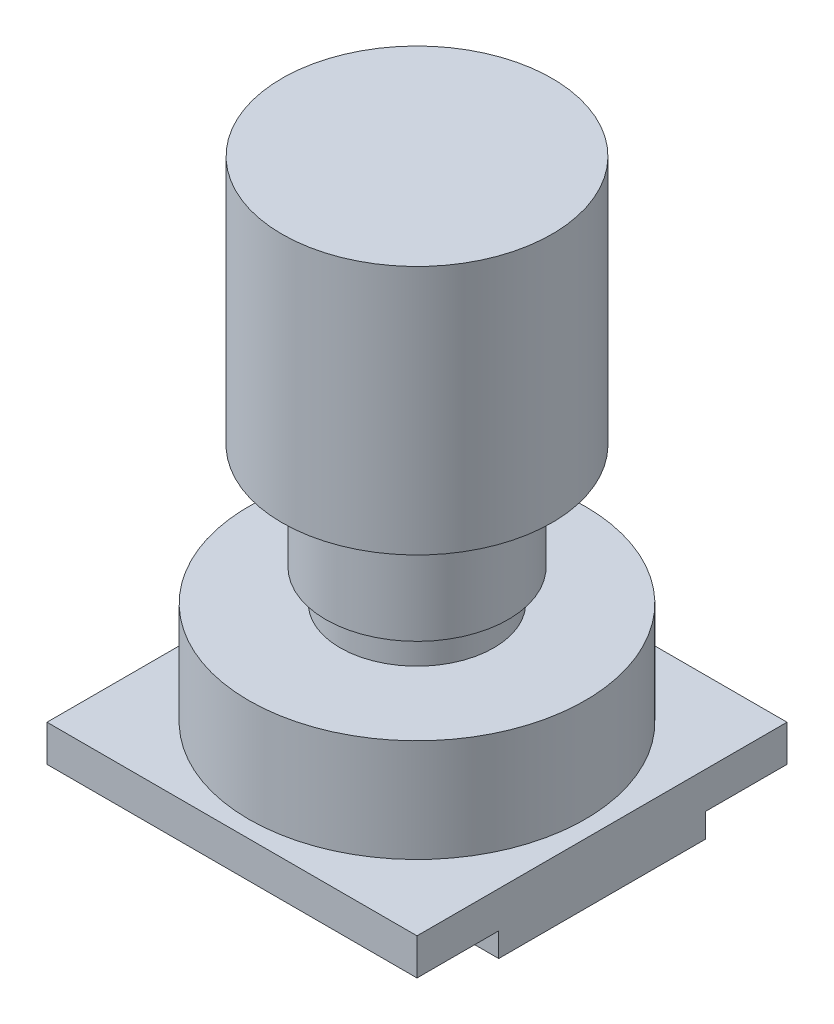
from build123d import *

# Parameters (mm, degrees)
SKETCH1_W           = 38.5
SKETCH1_H           = 38.5
BOSS_EXTRUDE1_DEPTH = 3.8
SKETCH2_R           = 17.5
BOSS_EXTRUDE2_DEPTH = 10.7
SKETCH3_R           = 8
BOSS_EXTRUDE3_DEPTH = 3.3
SKETCH4_R           = 9.5
BOSS_EXTRUDE4_DEPTH = 11
SKETCH5_R           = 14.05
BOSS_EXTRUDE5_DEPTH = 26
SKETCH7_W           = 6
SKETCH7_H           = 21.5
BOSS_EXTRUDE6_DEPTH = 2.5


with BuildPart() as part:
    # Sketch1 → Boss-Extrude1 (new body)
    with BuildSketch(Plane(origin=(0, 0, 0), x_dir=(1, 0, 0), z_dir=(0, 1, 0))):
        Rectangle(SKETCH1_W, SKETCH1_H)
    extrude(amount=BOSS_EXTRUDE1_DEPTH)

    # Sketch2 → Boss-Extrude2 (add)
    with BuildSketch(Plane(origin=(0, 3.8, 0), x_dir=(1, 0, 0), z_dir=(0, 1, 0))):
        Circle(SKETCH2_R)
    extrude(amount=BOSS_EXTRUDE2_DEPTH)

    # Sketch3 → Boss-Extrude3 (add)
    with BuildSketch(Plane(origin=(0, 14.5, 0), x_dir=(1, 0, 0), z_dir=(0, 1, 0))):
        Circle(SKETCH3_R)
    extrude(amount=BOSS_EXTRUDE3_DEPTH)

    # Sketch4 → Boss-Extrude4 (add)
    with BuildSketch(Plane(origin=(0, 17.8, 0), x_dir=(1, 0, 0), z_dir=(0, 1, 0))):
        Circle(SKETCH4_R)
    extrude(amount=BOSS_EXTRUDE4_DEPTH)

    # Sketch5 → Boss-Extrude5 (add)
    with BuildSketch(Plane(origin=(0, 28.8, 0), x_dir=(1, 0, 0), z_dir=(0, 1, 0))):
        Circle(SKETCH5_R)
    extrude(amount=BOSS_EXTRUDE5_DEPTH)

    # Sketch7 → Boss-Extrude6 (add)
    with BuildSketch(Plane.XZ):
        with Locations((16.25, 0)):
            Rectangle(SKETCH7_W, SKETCH7_H)
    extrude(amount=BOSS_EXTRUDE6_DEPTH)


solid = part.part
